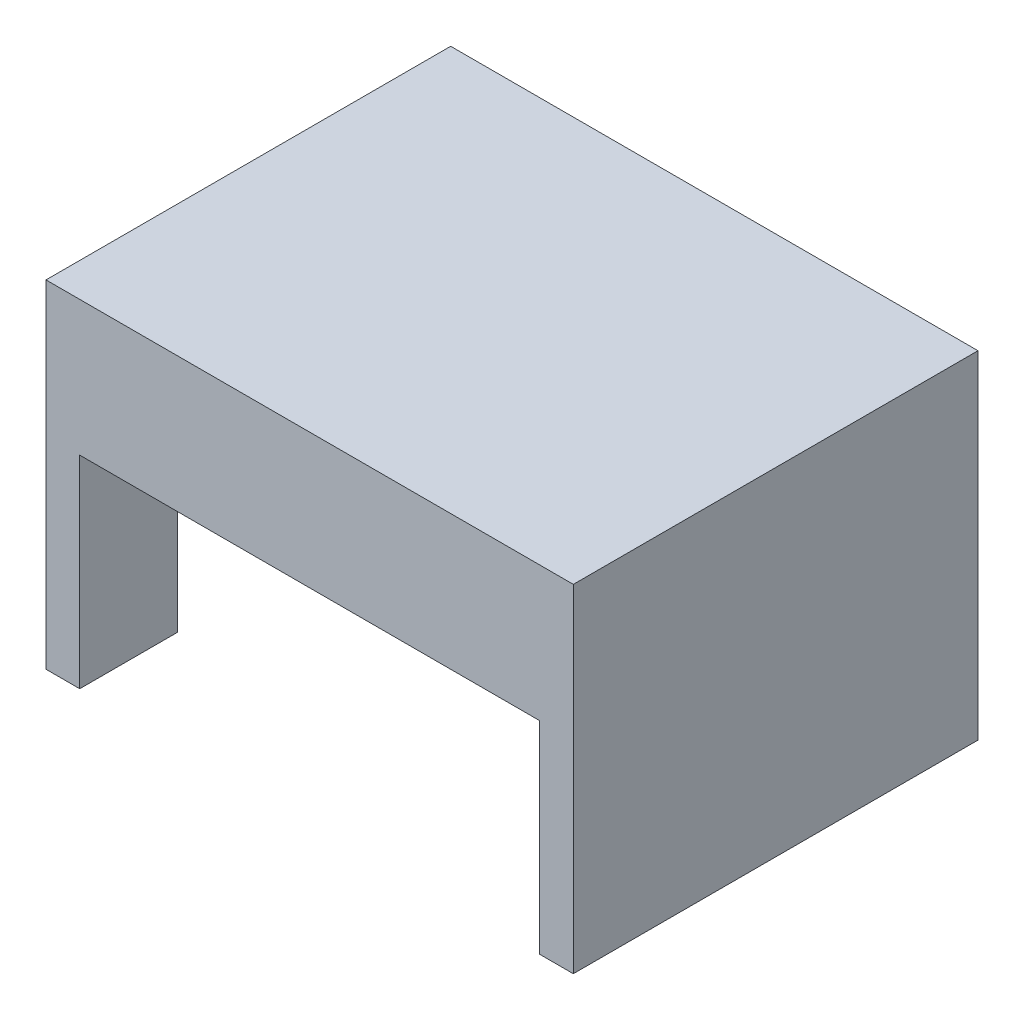
from build123d import *

# Parameters (mm, degrees)
SKETCH_1_W          = 5
SKETCH_1_H          = 30
EXTRUDE_1_DEPTH     = 60
SKETCH_2_W          = 68.186813186
SKETCH_2_H          = 31
CUT_EXTRUDE_1_DEPTH = 10
SKETCH_3_W          = 5
SKETCH_3_H          = 31
CUT_EXTRUDE_3_DEPTH = 40


with BuildPart() as part:
    # 草圖1 → 填料-伸長1 (new body)
    with BuildSketch(Plane.XY):
        Polygon((-56.41038016, 13.571428571), (-56.41038016, -6.428571429), (-51.41038016, -6.428571429), (16.776433026, -6.428571429), (21.776433026, -6.428571429), (21.776433026, 13.571428571), align=None)
        with Locations((-53.91038016, -21.428571429)):
            Rectangle(SKETCH_1_W, SKETCH_1_H)
        with Locations((19.276433026, -21.428571429)):
            Rectangle(SKETCH_1_W, SKETCH_1_H)
    extrude(amount=EXTRUDE_1_DEPTH)

    # 草圖2 → 除料-伸長1 (cut)
    with BuildSketch(Plane.XZ.offset(6.428571429)):
        with Locations((-17.316973567, 30)):
            Rectangle(SKETCH_2_W, SKETCH_2_H)
    extrude(amount=-CUT_EXTRUDE_1_DEPTH, mode=Mode.SUBTRACT)

    # 草圖3 → 除料-伸長3 (cut)
    with BuildSketch(Plane.XZ.offset(36.428571429)):
        with Locations((-53.91038016, 30)):
            Rectangle(SKETCH_3_W, SKETCH_3_H)
    extrude(amount=-CUT_EXTRUDE_3_DEPTH, mode=Mode.SUBTRACT)


solid = part.part
